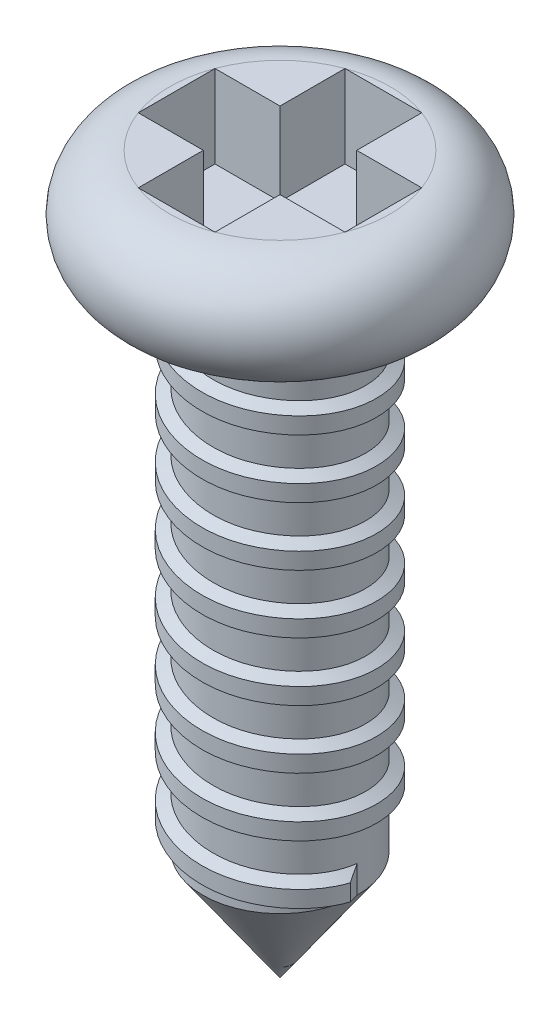
from build123d import *
from build123d.topology import SkipClean

# Parameters (mm, degrees)
SCREW_HEAD_INDENT_DEPTH    = 0.75
SCREW_BODY_SKETCH_R        = 0.7
SCREW_BODY_DEPTH           = 4.5
UPPER_THREAD_END_CUT_DEPTH = 0.125
LOWER_THREAD_END_CUT_DEPTH = 0.15


with BuildPart() as part:
    # Screw Head Sketch → Screw Head Revolve (revolve)
    with BuildSketch(Plane.XY, mode=Mode.PRIVATE) as screw_head_revolve_sk:
        with BuildLine():
            Line((0, 1), (0, 0))
            Line((0, 0), (-1, 0))
            ThreePointArc((-1, 0), (-1.5, 0.5), (-1, 1))
            Line((-1, 1), (0, 1))
        make_face()
    revolve(screw_head_revolve_sk.sketch.rotate(Axis((0, 1, 0), (0, -1, 0)), 270), axis=Axis((0, 1, 0), (0, -1, 0)))

    # Screw Head Indent Sketch → Screw Head Indent (cut)
    with BuildSketch(Plane(origin=(0, 1, 0), x_dir=(1, 0, 0), z_dir=(0, 1, 0))):
        Polygon((0.34794385, 0.34794385), (0.937515374, 0.34794385), (0.937515374, -0.34794385), (0.34794385, -0.34794385), (0.34794385, -0.937515374), (-0.34794385, -0.937515374), (-0.34794385, -0.34794385), (-0.937515374, -0.34794385), (-0.937515374, 0.34794385), (-0.34794385, 0.34794385), (-0.34794385, 0.937515374), (0.34794385, 0.937515374), align=None)
    extrude(amount=-SCREW_HEAD_INDENT_DEPTH, mode=Mode.SUBTRACT)

    # Screw Body Sketch → Screw Body (add)
    with BuildSketch(Plane.XZ):
        with Locations(Location((0, 0, 0), (0, 0, 270))):
            Circle(SCREW_BODY_SKETCH_R)
    extrude(amount=SCREW_BODY_DEPTH)

    # Screw Tip Sketch → Screw Tip (revolve)
    with BuildSketch(Plane.XY, mode=Mode.PRIVATE) as screw_tip_sk:
        Polygon((0, -4.5), (0, -5.5), (0.7, -4.5), align=None)
    revolve(screw_tip_sk.sketch.rotate(Axis((0, -4.5, 0), (0, -1, 0)), 90), axis=Axis((0, -4.5, 0), (0, -1, 0)))

    # Thread Sweep: sweep along a curve in space
    with SkipClean():  # the faces are left unmerged after this step: merging them gives an invalid solid
        with BuildLine() as thread_sweep_path:
            add(Edge.make_bspline(
                [(0.7, -0.125, 0), (0.7, -0.135997753, -0.091050627), (0.66355231, -0.158235591, -0.275115432), (0.507860951, -0.191397551, -0.507790463), (0.274852366, -0.224611706, -0.663571197), (0, -0.257811875, -0.718218784), (-0.274852366, -0.291015792, -0.663553666), (-0.507860951, -0.324218705, -0.507860588), (-0.66355231, -0.357421887, -0.274852464), (-0.718223845, -0.390624997, 2.6e-08), (-0.66355231, -0.423828126, 0.274852359), (-0.507860951, -0.45703125, 0.507860953), (-0.274852366, -0.490234375, 0.66355231), (0, -0.5234375, 0.718223845), (0.274852366, -0.556640625, 0.66355231), (0.507860951, -0.58984375, 0.507860951), (0.66355231, -0.623046875, 0.274852366), (0.718223845, -0.65625, 0), (0.66355231, -0.689453125, -0.274852366), (0.507860951, -0.72265625, -0.507860951), (0.274852366, -0.755859375, -0.66355231), (0, -0.7890625, -0.718223845), (-0.274852366, -0.822265625, -0.66355231), (-0.507860951, -0.85546875, -0.507860951), (-0.66355231, -0.888671875, -0.274852366), (-0.718223845, -0.921875, 0), (-0.66355231, -0.955078125, 0.274852366), (-0.507860951, -0.98828125, 0.507860951), (-0.274852366, -1.021484375, 0.66355231), (0, -1.0546875, 0.718223845), (0.274852366, -1.087890625, 0.66355231), (0.507860951, -1.12109375, 0.507860951), (0.66355231, -1.154296875, 0.274852366), (0.718223845, -1.1875, 0), (0.66355231, -1.220703125, -0.274852366), (0.507860951, -1.25390625, -0.507860951), (0.274852366, -1.287109375, -0.66355231), (0, -1.3203125, -0.718223845), (-0.274852366, -1.353515625, -0.66355231), (-0.507860951, -1.38671875, -0.507860951), (-0.66355231, -1.419921875, -0.274852366), (-0.718223845, -1.453125, 0), (-0.66355231, -1.486328125, 0.274852366), (-0.507860951, -1.51953125, 0.507860951), (-0.274852366, -1.552734375, 0.66355231), (0, -1.5859375, 0.718223845), (0.274852366, -1.619140625, 0.66355231), (0.507860951, -1.65234375, 0.507860951), (0.66355231, -1.685546875, 0.274852366), (0.718223845, -1.71875, 0), (0.66355231, -1.751953125, -0.274852366), (0.507860951, -1.78515625, -0.507860951), (0.274852366, -1.818359375, -0.66355231), (0, -1.8515625, -0.718223845), (-0.274852366, -1.884765625, -0.66355231), (-0.507860951, -1.91796875, -0.507860951), (-0.66355231, -1.951171875, -0.274852366), (-0.718223845, -1.984375, 0), (-0.66355231, -2.017578125, 0.274852366), (-0.507860951, -2.05078125, 0.507860951), (-0.274852366, -2.083984375, 0.66355231), (0, -2.1171875, 0.718223845), (0.274852366, -2.150390625, 0.66355231), (0.507860951, -2.18359375, 0.507860951), (0.66355231, -2.216796875, 0.274852366), (0.718223845, -2.25, 0), (0.66355231, -2.283203125, -0.274852366), (0.507860951, -2.31640625, -0.507860951), (0.274852366, -2.349609375, -0.66355231), (0, -2.3828125, -0.718223845), (-0.274852366, -2.416015625, -0.66355231), (-0.507860951, -2.44921875, -0.507860951), (-0.66355231, -2.482421875, -0.274852366), (-0.718223845, -2.515625, 0), (-0.66355231, -2.548828125, 0.274852366), (-0.507860951, -2.58203125, 0.507860951), (-0.274852366, -2.615234375, 0.66355231), (0, -2.6484375, 0.718223845), (0.274852366, -2.681640625, 0.66355231), (0.507860951, -2.71484375, 0.507860951), (0.66355231, -2.748046875, 0.274852366), (0.718223845, -2.78125, 0), (0.66355231, -2.814453125, -0.274852366), (0.507860951, -2.84765625, -0.507860951), (0.274852366, -2.880859375, -0.66355231), (0, -2.9140625, -0.718223845), (-0.274852366, -2.947265625, -0.66355231), (-0.507860951, -2.98046875, -0.507860951), (-0.66355231, -3.013671875, -0.274852366), (-0.718223845, -3.046875, 0), (-0.66355231, -3.080078125, 0.274852366), (-0.507860951, -3.11328125, 0.507860951), (-0.274852366, -3.146484375, 0.66355231), (0, -3.1796875, 0.718223845), (0.274852366, -3.212890625, 0.66355231), (0.507860951, -3.24609375, 0.507860951), (0.66355231, -3.279296875, 0.274852366), (0.718223845, -3.3125, 0), (0.66355231, -3.345703125, -0.274852366), (0.507860951, -3.37890625, -0.507860951), (0.274852366, -3.412109375, -0.66355231), (0, -3.4453125, -0.718223845), (-0.274852366, -3.478515625, -0.66355231), (-0.507860951, -3.51171875, -0.507860951), (-0.66355231, -3.544921875, -0.274852366), (-0.718223845, -3.578125, 0), (-0.66355231, -3.611328125, 0.274852366), (-0.507860951, -3.64453125, 0.507860951), (-0.274852366, -3.677734375, 0.66355231), (0, -3.7109375, 0.718223845), (0.274852366, -3.744140625, 0.66355231), (0.507860951, -3.77734375, 0.507860951), (0.66355231, -3.810546875, 0.274852366), (0.718223845, -3.84375, 0), (0.66355231, -3.876953125, -0.274852366), (0.507860951, -3.91015625, -0.507860951), (0.274852366, -3.943359375, -0.66355231), (0, -3.9765625, -0.718223845), (-0.274852366, -4.009765625, -0.66355231), (-0.507860951, -4.04296875, -0.507860953), (-0.66355231, -4.076171874, -0.274852359), (-0.718223845, -4.109375003, -2.6e-08), (-0.66355231, -4.142578113, 0.274852464), (-0.507860951, -4.175781295, 0.507860588), (-0.274852366, -4.208984208, 0.663553666), (0, -4.242188125, 0.718218784), (0.274852366, -4.275388294, 0.663571197), (0.507860951, -4.308602449, 0.507790463), (0.66355231, -4.341764409, 0.275115432), (0.7, -4.364002247, 0.091050627), (0.7, -4.375, 0)],
                knots=[0, 0, 0, 0, 0.0078125, 0.015625, 0.0234375, 0.03125, 0.0390625, 0.046875, 0.0546875, 0.0625, 0.0703125, 0.078125, 0.0859375, 0.09375, 0.1015625, 0.109375, 0.1171875, 0.125, 0.1328125, 0.140625, 0.1484375, 0.15625, 0.1640625, 0.171875, 0.1796875, 0.1875, 0.1953125, 0.203125, 0.2109375, 0.21875, 0.2265625, 0.234375, 0.2421875, 0.25, 0.2578125, 0.265625, 0.2734375, 0.28125, 0.2890625, 0.296875, 0.3046875, 0.3125, 0.3203125, 0.328125, 0.3359375, 0.34375, 0.3515625, 0.359375, 0.3671875, 0.375, 0.3828125, 0.390625, 0.3984375, 0.40625, 0.4140625, 0.421875, 0.4296875, 0.4375, 0.4453125, 0.453125, 0.4609375, 0.46875, 0.4765625, 0.484375, 0.4921875, 0.5, 0.5078125, 0.515625, 0.5234375, 0.53125, 0.5390625, 0.546875, 0.5546875, 0.5625, 0.5703125, 0.578125, 0.5859375, 0.59375, 0.6015625, 0.609375, 0.6171875, 0.625, 0.6328125, 0.640625, 0.6484375, 0.65625, 0.6640625, 0.671875, 0.6796875, 0.6875, 0.6953125, 0.703125, 0.7109375, 0.71875, 0.7265625, 0.734375, 0.7421875, 0.75, 0.7578125, 0.765625, 0.7734375, 0.78125, 0.7890625, 0.796875, 0.8046875, 0.8125, 0.8203125, 0.828125, 0.8359375, 0.84375, 0.8515625, 0.859375, 0.8671875, 0.875, 0.8828125, 0.890625, 0.8984375, 0.90625, 0.9140625, 0.921875, 0.9296875, 0.9375, 0.9453125, 0.953125, 0.9609375, 0.96875, 0.9765625, 0.984375, 0.9921875, 1, 1, 1, 1], degree=3))
        # Thread Profile → Thread Sweep (sweep)
        with BuildSketch(Plane.XY):
            Polygon((0.7, 0), (0.7, -0.25), (0.8, -0.2), (0.8, -0.05), align=None)
        sweep(path=thread_sweep_path.line, is_frenet=True)

    # Upper Thread End Cut Profile → Upper Thread End Cut (cut, symmetric)
    with BuildSketch(Plane(origin=(0, -0.125, 0), x_dir=(-1, 0, 0), z_dir=(0, -1, 0))):
        Polygon((-0.7, 0), (-0.8, 0.173205081), (-0.8, 0), align=None)
    extrude(amount=UPPER_THREAD_END_CUT_DEPTH, both=True, mode=Mode.SUBTRACT)

    # Lower Thread End Cut Profile → Lower Thread End Cut (cut, symmetric)
    with BuildSketch(Plane(origin=(0, -4.375, 0), x_dir=(-1, 0, 0), z_dir=(0, -1, 0))):
        Polygon((-0.7, 0), (-0.8, 0), (-0.8, -0.173205081), align=None)
    extrude(amount=LOWER_THREAD_END_CUT_DEPTH, both=True, mode=Mode.SUBTRACT)


solid = part.part
